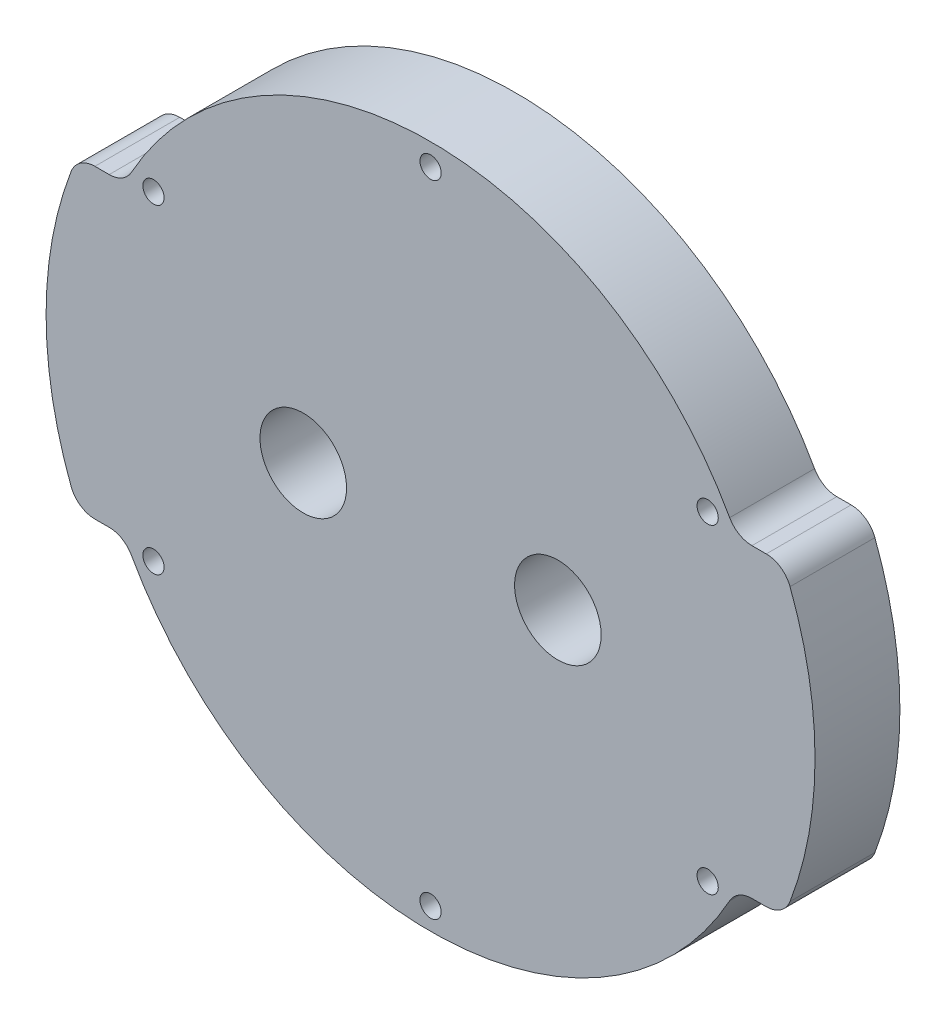
from build123d import *

# Parameters (mm, degrees)
SKETCH_1_R          = 45.3
EXTRUDE_1_DEPTH     = 10
CUT_EXTRUDE_1_DEPTH = 11
FILLET_1_R          = 3
SKETCH_3_R          = 1.25
CUT_EXTRUDE_2_DEPTH = 11
SKETCH_4_R          = 5.1
CUT_EXTRUDE_3_DEPTH = 11


with BuildPart() as part:
    # 草图1 → 凸台-拉伸1 (new body)
    with BuildSketch(Plane.XY):
        Circle(SKETCH_1_R)
    extrude(amount=EXTRUDE_1_DEPTH)

    # 草图2 → 切除-拉伸1 (cut, through all)
    with BuildSketch(Plane.XY.offset(10)):
        with BuildLine():
            Line((-36.056760808, 18), (-41.570301899, 18))
            ThreePointArc((-41.570301899, 18), (0, 45.3), (41.570301899, 18))
            Line((41.570301899, 18), (36.056760808, 18))
            ThreePointArc((36.056760808, 18), (0, 40.3), (-36.056760808, 18))
        make_face()
        with BuildLine():
            Line((-36.056760808, -18), (-41.734622438, -18))
            ThreePointArc((-41.734622438, -18), (0, -45.450838386), (41.734622438, -18))
            Line((41.734622438, -18), (36.056760808, -18))
            ThreePointArc((36.056760808, -18), (0, -40.3), (-36.056760808, -18))
        make_face()
    extrude(amount=-CUT_EXTRUDE_1_DEPTH, mode=Mode.SUBTRACT)

    # 圆角1
    fillet_1_edges = [part.edges().sort_by_distance(p)[0] for p in [
        (36.056760808, 18, 5),
        (-36.056760808, 18, 5),
        (-41.570301899, 18, 5),
        (41.570301899, 18, 5),
        (41.570301899, -18, 5),
        (36.056760808, -18, 5),
        (-41.570301899, -18, 5),
        (-36.056760808, -18, 5),
    ]]
    fillet(fillet_1_edges, radius=FILLET_1_R)

    # 草图3 → 切除-拉伸2 (cut, through all)
    with BuildSketch(Plane.XY.offset(10)):
        with Locations((0, 37.7)):
            Circle(SKETCH_3_R)
        with Locations((32.649157723, 18.85)):
            Circle(SKETCH_3_R)
        with Locations((32.649157723, -18.85)):
            Circle(SKETCH_3_R)
        with Locations((0, -37.7)):
            Circle(SKETCH_3_R)
        with Locations((-32.649157723, -18.85)):
            Circle(SKETCH_3_R)
        with Locations((-32.649157723, 18.85)):
            Circle(SKETCH_3_R)
    extrude(amount=-CUT_EXTRUDE_2_DEPTH, mode=Mode.SUBTRACT)

    # 草图4 → 切除-拉伸3 (cut, through all)
    with BuildSketch(Plane.XY.offset(10)):
        with Locations((-15, 0)):
            Circle(SKETCH_4_R)
        with Locations((15, 0)):
            Circle(SKETCH_4_R)
    extrude(amount=-CUT_EXTRUDE_3_DEPTH, mode=Mode.SUBTRACT)


solid = part.part
